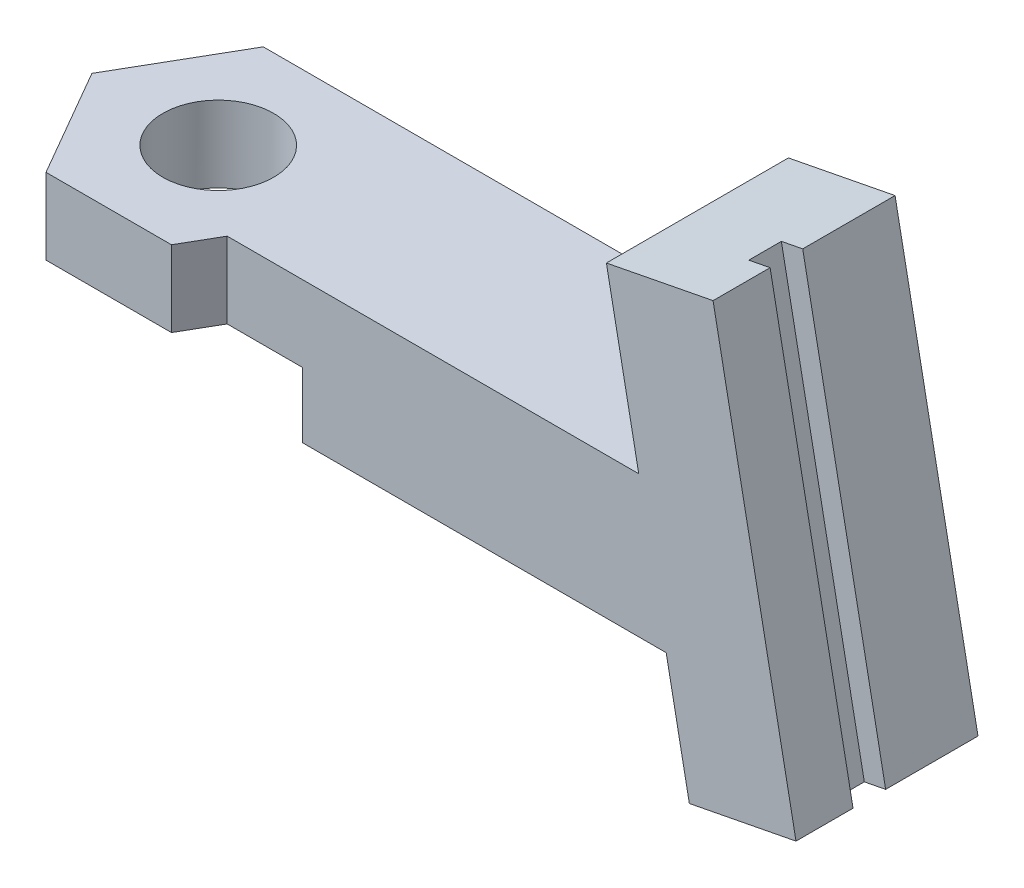
from build123d import *

# Parameters (mm, degrees)
SKETCH1_W                = 25
SKETCH1_H                = 6.75
BOSS_EXTRUDE1_DEPTH      = 6.5
BOSS_EXTRUDE3_DEPTH      = 3.375
BOSS_EXTRUDE3_DEPTH_BACK = 5
SKETCH4_W                = 1
SKETCH4_H                = 1.5
CUT_EXTRUDE1_DEPTH       = 23
BOSS_EXTRUDE4_DEPTH      = 6.5
SKETCH6_R                = 2.55
CUT_EXTRUDE2_DEPTH       = 10
BOSS_EXTRUDE5_REACH      = 12
CUT_EXTRUDE3_DEPTH       = 3


with BuildPart() as part:
    # Sketch1 → Boss-Extrude1 (new body)
    with BuildSketch(Plane(origin=(0, 0, 0), x_dir=(1, 0, 0), z_dir=(0, 1, 0))):
        with Locations((12.5, -3.375)):
            Rectangle(SKETCH1_W, SKETCH1_H)
    extrude(amount=BOSS_EXTRUDE1_DEPTH)

    # Sketch3 → Boss-Extrude3 (add, two sides)
    with BuildSketch(Plane.XY.offset(3.375)) as boss_extrude3_sk:
        Polygon((21.275684175, 14.155521181), (26.183820092, 15.109566157), (30, -4.522977512), (25.091864083, -5.477022488), align=None)
    extrude(amount=BOSS_EXTRUDE3_DEPTH)
    extrude(boss_extrude3_sk.sketch, amount=-BOSS_EXTRUDE3_DEPTH_BACK)

    # Sketch4 → Cut-Extrude1 (cut)
    with BuildSketch(Plane(origin=(-1.876769127, 9.65514015, 0), x_dir=(0.981627183, 0.190808995, 0), z_dir=(-0.190808995, 0.981627183, 0))):
        with Locations((28.085790708, -3.375)):
            Rectangle(SKETCH4_W, SKETCH4_H)
    extrude(amount=-CUT_EXTRUDE1_DEPTH, mode=Mode.SUBTRACT)

    # Sketch5 → Boss-Extrude4 (add)
    with BuildSketch(Plane(origin=(0, 6.5, 0), x_dir=(1, 0, 0), z_dir=(0, 1, 0))):
        Polygon((-5.773502692, -3.375), (-2.886751346, -8.375), (2.886751346, -8.375), (5.773502692, -3.375), (2.886751346, 1.625), (-2.886751346, 1.625), align=None)
    extrude(amount=-BOSS_EXTRUDE4_DEPTH)

    # Sketch6 → Cut-Extrude2 (cut)
    with BuildSketch(Plane(origin=(0, 6.5, 0), x_dir=(1, 0, 0), z_dir=(0, 1, 0))):
        with Locations((0, -3.335615973)):
            Circle(SKETCH6_R)
    extrude(amount=-CUT_EXTRUDE2_DEPTH, mode=Mode.SUBTRACT)

    # Sketch7 → Boss-Extrude5 (add, up to next)
    with BuildSketch(Plane(origin=(0, 0, -1.625), x_dir=(-1, 0, 0), z_dir=(0, 0, -1)), mode=Mode.PRIVATE) as boss_extrude5_sk1:
        Polygon((-2.886751346, 0), (-24.027238758, 0), (-25.091864083, -5.477022488), (-30, -4.522977512), (-26.183820092, 15.109566157), (-21.275684175, 14.155521181), (-22.763766749, 6.5), (-2.886751346, 6.5), align=None)
    boss_extrude5_tool1 = extrude(boss_extrude5_sk1.sketch, amount=-BOSS_EXTRUDE5_REACH, mode=Mode.PRIVATE) - part.part
    add(boss_extrude5_tool1.solids().sort_by_distance((18.499322, 3.902268, -1.625))[0])

    # Sketch8 → Cut-Extrude3 (cut)
    with BuildSketch(Plane(origin=(0, 0, 0), x_dir=(-1, 0, 0), z_dir=(0, -1, 0))):
        Polygon((-4.618802154, -11.375), (4.618802154, -11.375), (9.237604307, -3.375), (4.618802154, 4.625), (-4.618802154, 4.625), (-9.237604307, -3.375), align=None)
    extrude(amount=-CUT_EXTRUDE3_DEPTH, mode=Mode.SUBTRACT)


solid = part.part
